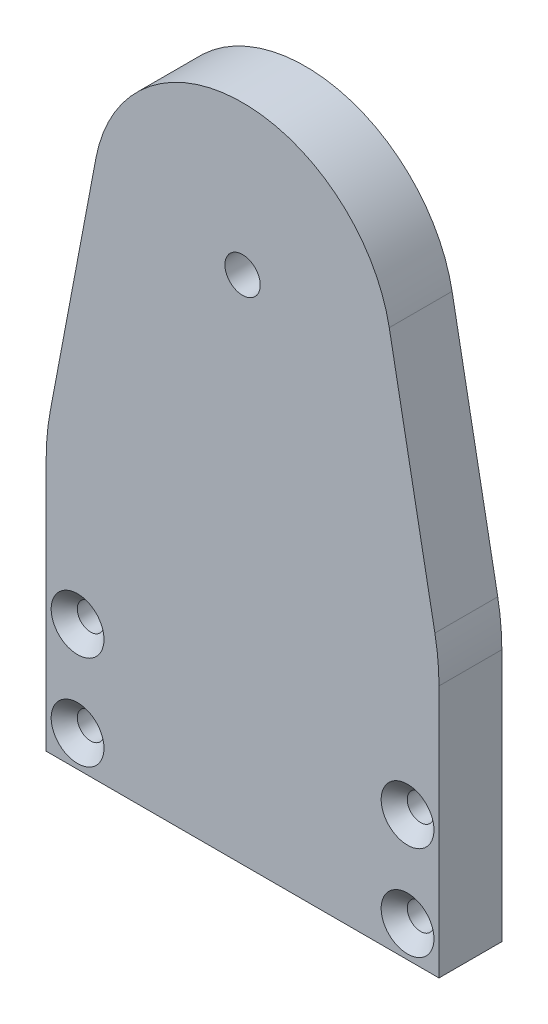
from build123d import *

# Parameters (mm, degrees)
EXTRUDE_1_DEPTH              = 8
FILLET_1_R                   = 30
SKETCH_2_R                   = 14
CUT_EXTRUDE_1_DEPTH          = 4
HOLE_WIZARD_M4_1_D           = 4.5
HOLE_WIZARD_M3_1_D           = 3.4
HOLE_WIZARD_M3_1_DEPTH       = 8
HOLE_WIZARD_M3_1_CSINK_D     = 6.72
HOLE_WIZARD_M3_1_CSINK_ANGLE = 90
HOLE_WIZARD_M3_1_2_D         = 2.5
HOLE_WIZARD_M3_1_2_DEPTH     = 8.5
HOLE_WIZARD_M3_1_2_TIP       = 0.751075774


with BuildPart() as part:
    # 스케치1 → 보스-돌출1 (new body)
    with BuildSketch(Plane.XY):
        with BuildLine():
            Line((0, 35), (0, 0))
            Line((0, 0), (50, 0))
            Line((50, 0), (50, 35))
            Line((50, 35), (43.670126691, 68.525105576))
            ThreePointArc((43.670126691, 68.525105576), (25, 84), (6.329873309, 68.525105576))
            Line((6.329873309, 68.525105576), (0, 35))
        make_face()
    extrude(amount=EXTRUDE_1_DEPTH)

    # 필렛1
    fillet_1_edges = [part.edges().sort_by_distance(p)[0] for p in [
        (50, 35, 4),
        (0, 35, 4),
    ]]
    fillet(fillet_1_edges, radius=FILLET_1_R)

    # 스케치2 → 컷-돌출1 (cut)
    with BuildSketch(Plane(origin=(0, 0, 0), x_dir=(-1, 0, 0), z_dir=(0, 0, -1))):
        with Locations((-25, 65)):
            Circle(SKETCH_2_R)
    extrude(amount=-CUT_EXTRUDE_1_DEPTH, mode=Mode.SUBTRACT)

    # M4 여유 구멍1 (through all)
    with Locations(Plane.XY.offset(8)):
        with Locations((25, 65)):
            Hole(HOLE_WIZARD_M4_1_D / 2)

    # Hole Wizard M3 _ _ _ _ _ _ _1
    with Locations(Plane.XY.offset(8)):
        with Locations((4, 16), (4, 4), (46, 4), (46, 16)):
            CounterSinkHole(HOLE_WIZARD_M3_1_D / 2, HOLE_WIZARD_M3_1_CSINK_D / 2, depth=HOLE_WIZARD_M3_1_DEPTH, counter_sink_angle=HOLE_WIZARD_M3_1_CSINK_ANGLE)

    # Hole Wizard M3 _ _1 2
    with Locations(Plane(origin=(0, 0, 0), x_dir=(-1, 0, 0), z_dir=(0, -1, 0))):
        with Locations((-38, -4), (-12, -4)):
            Hole(HOLE_WIZARD_M3_1_2_D / 2, depth=HOLE_WIZARD_M3_1_2_DEPTH)
            with Locations((0, 0, -(HOLE_WIZARD_M3_1_2_DEPTH + HOLE_WIZARD_M3_1_2_TIP / 2))):  # 118° drill point
                Cone(0, HOLE_WIZARD_M3_1_2_D / 2, HOLE_WIZARD_M3_1_2_TIP, mode=Mode.SUBTRACT)


solid = part.part
